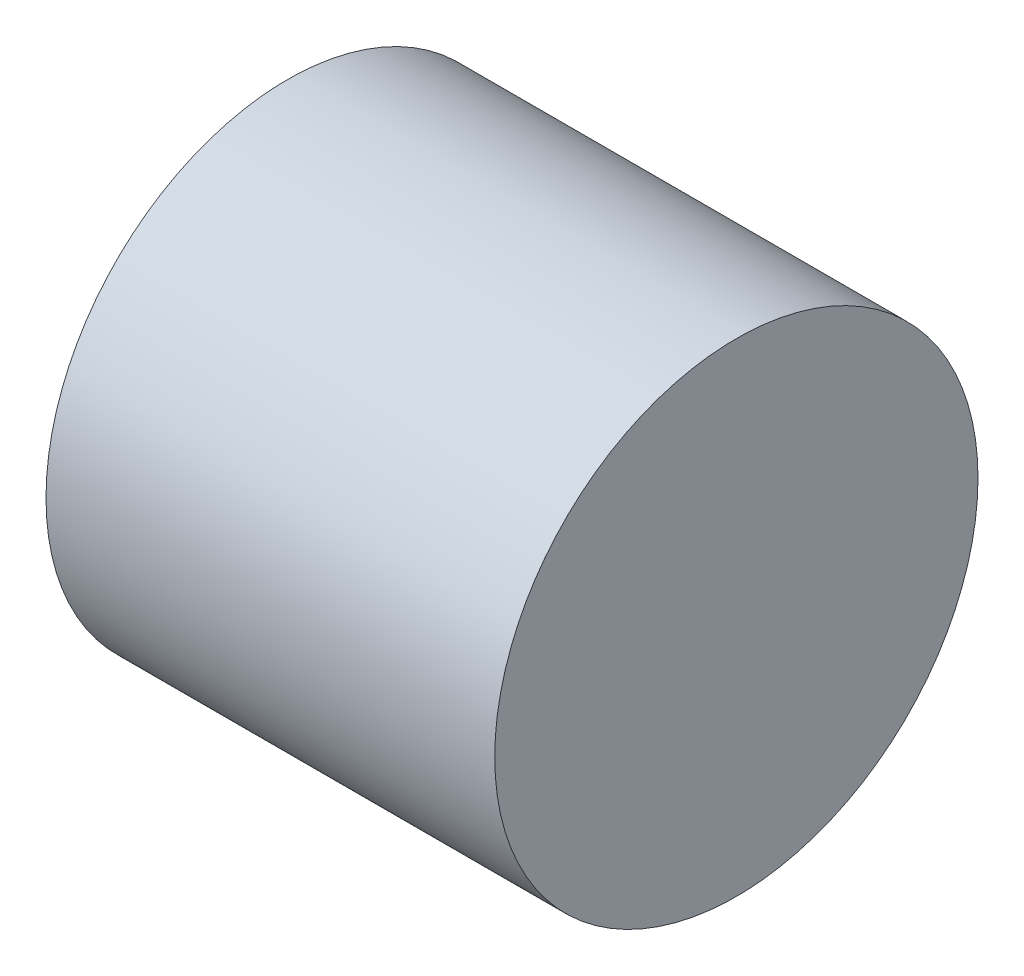
from build123d import *

# Parameters (mm, degrees)
SKETCH1_R           = 7
BOSS_EXTRUDE1_DEPTH = 13


with BuildPart() as part:
    # Sketch1 → Boss-Extrude1 (new body)
    with BuildSketch(Plane(origin=(0, 0, 0), x_dir=(0, 0, -1), z_dir=(1, 0, 0))):
        Circle(SKETCH1_R)
    extrude(amount=BOSS_EXTRUDE1_DEPTH)


solid = part.part
